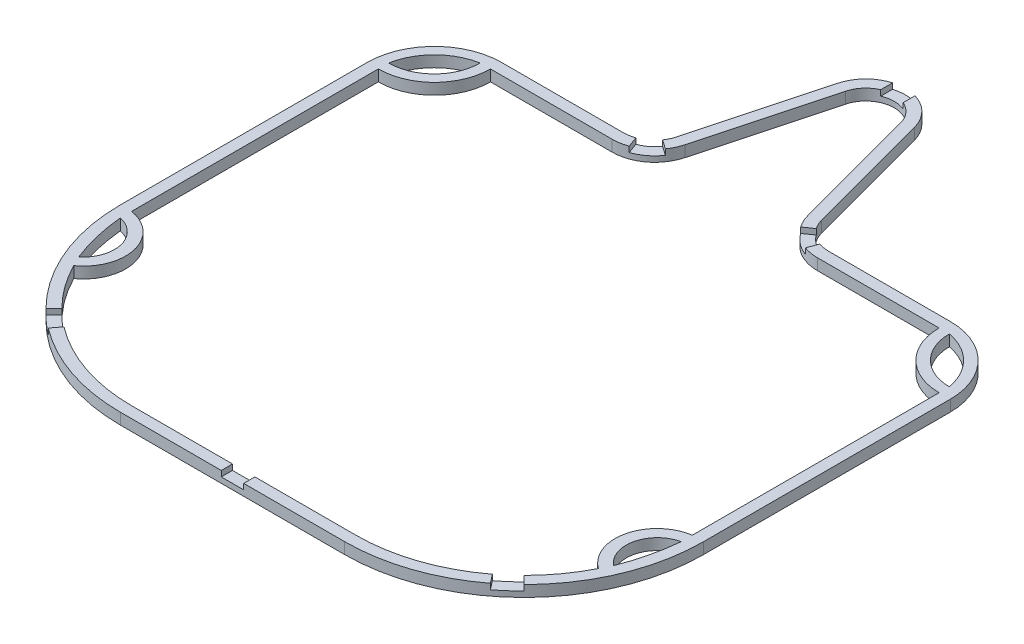
from build123d import *

# Parameters (mm, degrees)
BOSS_EXTRUDE1_DEPTH = 1.25
BOSS_EXTRUDE5_DEPTH = 2.5
SKETCH6_W           = 5
SKETCH6_H           = 4
CUT_EXTRUDE1_DEPTH  = 1.25
CUT_EXTRUDE2_DEPTH  = 2.5


with BuildPart() as part:
    # Sketch2 → Boss-Extrude1 (new body, symmetric)
    with BuildSketch(Plane(origin=(0, 0, 0), x_dir=(1, 0, 0), z_dir=(0, 1, 0))):
        with BuildLine():
            Line((-16.109808132, 47.688266684), (-8.537351427, 75.949059844))
            ThreePointArc((-8.537351427, 75.949059844), (0, 82.5), (8.537351427, 75.949059844))
            Line((8.537351427, 75.949059844), (16.109808132, 47.688266684))
            ThreePointArc((16.109808132, 47.688266684), (18.609958913, 43.946526618), (22.871288916, 42.5))
            Line((22.871288916, 42.5), (50, 42.5))
            ThreePointArc((50, 42.5), (60.606601718, 38.106601718), (65, 27.5))
            Line((65, 27.5), (65, -27.5))
            ThreePointArc((65, -27.5), (53.284271247, -55.784271247), (25, -67.5))
            Line((25, -67.5), (-25, -67.5))
            ThreePointArc((-25, -67.5), (-53.284271247, -55.784271247), (-65, -27.5))
            Line((-65, -27.5), (-65, 27.5))
            ThreePointArc((-65, 27.5), (-60.606601718, 38.106601718), (-50, 42.5))
            Line((-50, 42.5), (-22.871288916, 42.5))
            ThreePointArc((-22.871288916, 42.5), (-18.609958913, 43.946526618), (-16.109808132, 47.688266684))
        make_face()
        with BuildLine():
            Line((6.122536861, 75.302012231), (13.694993566, 47.041219072))
            ThreePointArc((13.694993566, 47.041219072), (17.08805534, 41.963143267), (22.871288916, 40))
            Line((22.871288916, 40), (50, 40))
            ThreePointArc((50, 40), (58.838834765, 36.338834765), (62.5, 27.5))
            Line((62.5, 27.5), (62.5, -27.5))
            ThreePointArc((62.5, -27.5), (51.516504294, -54.016504294), (25, -65))
            Line((25, -65), (-25, -65))
            ThreePointArc((-25, -65), (-51.516504294, -54.016504294), (-62.5, -27.5))
            Line((-62.5, -27.5), (-62.5, 27.5))
            ThreePointArc((-62.5, 27.5), (-58.838834765, 36.338834765), (-50, 40))
            Line((-50, 40), (-22.871288916, 40))
            ThreePointArc((-22.871288916, 40), (-17.08805534, 41.963143267), (-13.694993566, 47.041219072))
            Line((-13.694993566, 47.041219072), (-6.122536861, 75.302012231))
            ThreePointArc((-6.122536861, 75.302012231), (0, 80), (6.122536861, 75.302012231))
        make_face(mode=Mode.SUBTRACT)
    extrude(amount=BOSS_EXTRUDE1_DEPTH, both=True)

    # Sketch5 → Boss-Extrude5 (add)
    with BuildSketch(Plane(origin=(0, 1.25, 0), x_dir=(1, 0, 0), z_dir=(0, 1, 0))):
        with BuildLine():
            ThreePointArc((-62.5, 27.5), (-53.661165235, 31.161165235), (-50, 40))
            ThreePointArc((-50, 40), (-58.838834765, 36.338834765), (-62.5, 27.5))
        make_face()
        with BuildLine():
            ThreePointArc((50, 40), (53.661165235, 31.161165235), (62.5, 27.5))
            ThreePointArc((62.5, 27.5), (58.838834765, 36.338834765), (50, 40))
        make_face()
        with BuildLine():
            ThreePointArc((-62.5, -27.5), (-54.791585286, -34.595919329), (-58.473512014, -44.404851181))
            ThreePointArc((-58.473512014, -44.404851181), (-61.479492188, -36.188880811), (-62.5, -27.5))
        make_face()
        with BuildLine():
            ThreePointArc((62.5, -27.5), (54.791585286, -34.595919329), (58.473512014, -44.404851181))
            ThreePointArc((58.473512014, -44.404851181), (61.479492187, -36.188880811), (62.5, -27.5))
        make_face()
    extrude(amount=-BOSS_EXTRUDE5_DEPTH)

    # Sketch6 → Cut-Extrude1 (cut)
    with BuildSketch(Plane(origin=(0, 1.25, 0), x_dir=(1, 0, 0), z_dir=(0, 1, 0))):
        with Locations((0, 81.25)):
            Rectangle(SKETCH6_W, SKETCH6_H)
        with BuildLine():
            Line((-20.493193447, 42.916333701), (-19.643873637, 40.565024308))
            ThreePointArc((-19.643873637, 40.565024308), (-17.08805534, 41.963143267), (-15.076081678, 44.070014354))
            Line((-15.076081678, 44.070014354), (-17.127452004, 45.498957945))
            ThreePointArc((-17.127452004, 45.498957945), (-18.609958913, 43.946526618), (-20.493193447, 42.916333701))
        make_face()
        with BuildLine():
            Line((20.493193447, 42.916333701), (19.643873637, 40.565024308))
            ThreePointArc((19.643873637, 40.565024308), (17.08805534, 41.963143267), (15.076081678, 44.070014354))
            Line((15.076081678, 44.070014354), (17.127452004, 45.498957945))
            ThreePointArc((17.127452004, 45.498957945), (18.609958913, 43.946526618), (20.493193447, 42.916333701))
        make_face()
        with BuildLine():
            Line((-53.284271247, -55.784271247), (-51.516504294, -54.016504294))
            ThreePointArc((-51.516504294, -54.016504294), (-49.689746158, -55.725280064), (-47.753133619, -57.308470449))
            Line((-47.753133619, -57.308470449), (-49.270009194, -59.295701812))
            ThreePointArc((-49.270009194, -59.295701812), (-51.335729235, -57.606965401), (-53.284271247, -55.784271247))
        make_face()
        with BuildLine():
            Line((49.270009194, -59.295701812), (47.753133619, -57.308470449))
            ThreePointArc((47.753133619, -57.308470449), (49.689746158, -55.725280064), (51.516504294, -54.016504294))
            Line((51.516504294, -54.016504294), (53.284271247, -55.784271247))
            ThreePointArc((53.284271247, -55.784271247), (51.335729235, -57.606965401), (49.270009194, -59.295701812))
        make_face()
        with Locations((0, -66.5)):
            Rectangle(SKETCH6_W, SKETCH6_H)
    extrude(amount=-CUT_EXTRUDE1_DEPTH, mode=Mode.SUBTRACT)

    # Sketch7 → Cut-Extrude2 (cut)
    with BuildSketch(Plane(origin=(0, 1.25, 0), x_dir=(1, 0, 0), z_dir=(0, 1, 0))):
        with BuildLine():
            ThreePointArc((-62.5, 29.791666667), (-55.281618275, 32.781618275), (-52.291666667, 40))
            ThreePointArc((-52.291666667, 40), (-58.986148678, 36.486148678), (-62.5, 29.791666667))
        make_face()
        with BuildLine():
            ThreePointArc((52.291666667, 40), (58.986148678, 36.486148678), (62.5, 29.791666667))
            ThreePointArc((62.5, 29.791666667), (55.281618275, 32.781618275), (52.291666667, 40))
        make_face()
        with BuildLine():
            ThreePointArc((-59.600502093, -42.173283714), (-57.223551432, -35.175178049), (-62.5, -30))
            ThreePointArc((-62.5, -30), (-61.479492188, -36.188880811), (-59.600502093, -42.173283714))
        make_face()
        with BuildLine():
            ThreePointArc((62.5, -30), (61.479492187, -36.188880811), (59.600502093, -42.173283714))
            ThreePointArc((59.600502093, -42.173283714), (57.223551432, -35.175178049), (62.5, -30))
        make_face()
    extrude(amount=-CUT_EXTRUDE2_DEPTH, mode=Mode.SUBTRACT)


solid = part.part
